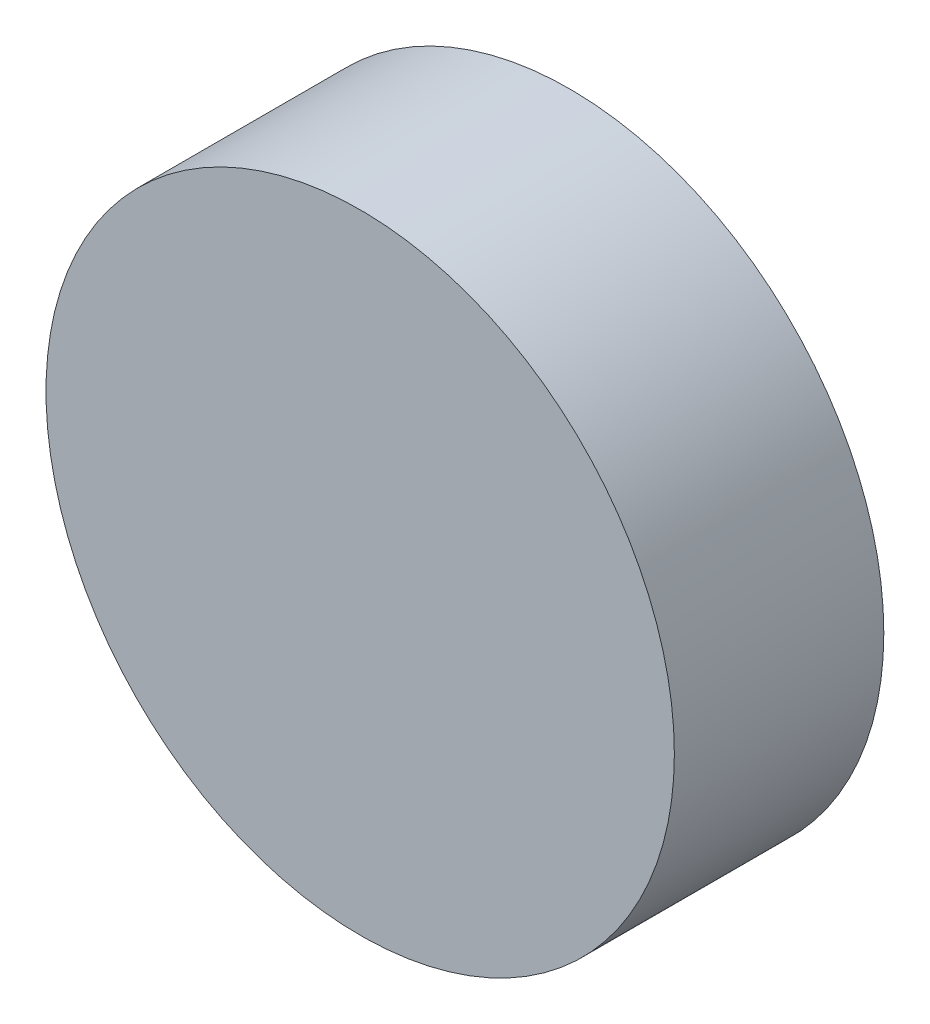
from build123d import *

# Parameters (mm, degrees)
SKETCH1_R           = 15
BOSS_EXTRUDE1_DEPTH = 10


with BuildPart() as part:
    # Sketch1 → Boss-Extrude1 (new body)
    with BuildSketch(Plane.XY):
        Circle(SKETCH1_R)
    extrude(amount=BOSS_EXTRUDE1_DEPTH)


solid = part.part
